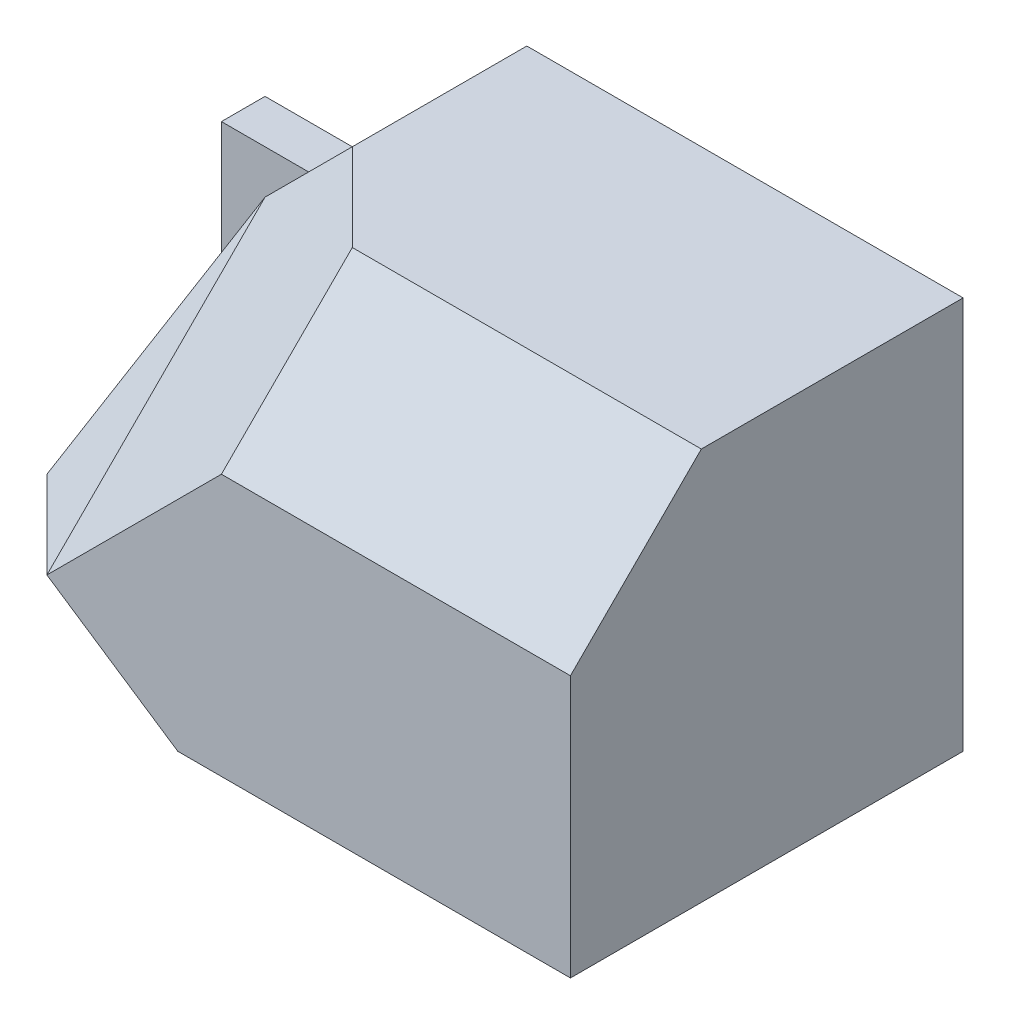
from build123d import *

# Parameters (mm, degrees)
BOSS_EXTRUDE1_DEPTH = 9
CUT_EXTRUDE1_DEPTH  = 8
CUT_EXTRUDE2_DEPTH  = 8
CUT_EXTRUDE3_DEPTH  = 8
CUT_EXTRUDE4_DEPTH  = 8
CUT_EXTRUDE5_DEPTH  = 2


with BuildPart() as part:
    # Sketch1 → Boss-Extrude1 (new body)
    with BuildSketch(Plane.XY):
        Polygon((-6, 0.5), (-8, 0.5), (-8, -4.5), (8, -4.5), (8, 4.5), (-2, 4.5), align=None)
    extrude(amount=BOSS_EXTRUDE1_DEPTH)

    # Sketch2 → Cut-Extrude1 (cut)
    with BuildSketch(Plane.XY.offset(9)):
        Polygon((-8, 0.5), (-6, 0.5), (-8, -4.5), align=None)
    extrude(amount=-CUT_EXTRUDE1_DEPTH, mode=Mode.SUBTRACT)

    # 3DSketch1 → Cut-Extrude2 (cut, along a direction that is not the sketch's normal)
    with BuildSketch(Plane(origin=(-8, -4.5, 5), x_dir=(0.464990554975277, 0.8137334712067351, -0.3487429162314579), z_dir=(0.5773502691896258, -0.5773502691896257, -0.5773502691896258))):
        Polygon((0, 0), (6.044877215, -1.208080899), (8.602325267, 0), (2.78994333, 4.026936331), (0.232495277, 2.818855432), align=None)
    extrude(amount=-CUT_EXTRUDE2_DEPTH, dir=(0, 0, -1), mode=Mode.SUBTRACT)

    # 3DSketch2 → Cut-Extrude3 (cut, along a direction that is not the sketch's normal)
    with BuildSketch(Plane(origin=(-4, -2.5, 9), x_dir=(0.2264554068289193, 0.7925939239012171, -0.5661385170722979), z_dir=(0.5773502691896256, -0.5773502691896258, -0.5773502691896258))):
        Polygon((0, 0), (6.793662205, -1.961161351), (8.831760866, 0), (8.152394646, 2.745625892), (4.076197323, 3.922322703), align=None)
    extrude(amount=-CUT_EXTRUDE3_DEPTH, dir=(0, 0, -1), mode=Mode.SUBTRACT)

    # Sketch3 → Cut-Extrude4 (cut)
    with BuildSketch(Plane.ZY):
        Polygon((9, 1.5), (6, 4.5), (9, 4.5), align=None)
    extrude(amount=-CUT_EXTRUDE4_DEPTH, mode=Mode.SUBTRACT)

    # Sketch4 → Cut-Extrude5 (cut)
    with BuildSketch(Plane.XY.offset(9)):
        Polygon((-4, -2.5), (-1, -4.5), (-6, -4.5), align=None)
    extrude(amount=-CUT_EXTRUDE5_DEPTH, mode=Mode.SUBTRACT)


solid = part.part
